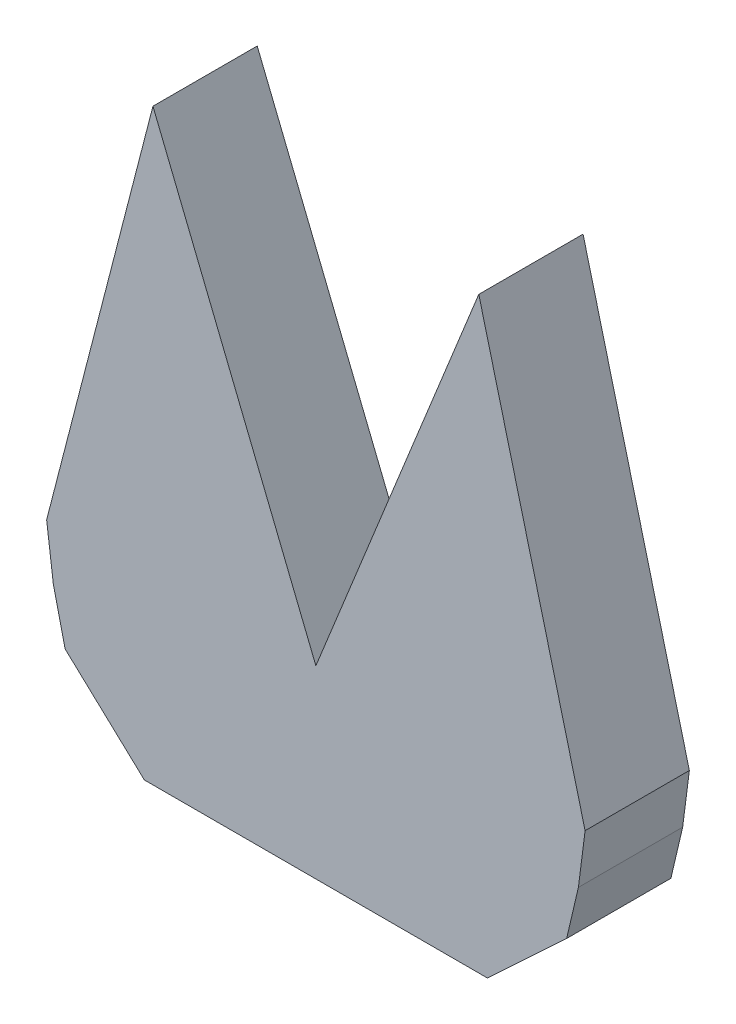
from build123d import *

# Parameters (mm, degrees)
BOSS_EXTRUDE1_DEPTH = 24


with BuildPart() as part:
    # Sketch4 → Boss-Extrude1 (new body)
    with BuildSketch(Plane.XY):
        Polygon((39.48, 0), (-39.48, 0), (-57.72489212, 16.99649249), (-60.433223771, 28.545236268), (-61.974925887, 40.617187081), (-37.504287486, 135.306298684), (0, 42.508472631), (37.504287486, 135.306298684), (61.974925887, 40.617187081), (60.433223771, 28.545236268), (57.72489212, 16.99649249), align=None)
    extrude(amount=BOSS_EXTRUDE1_DEPTH)


solid = part.part
